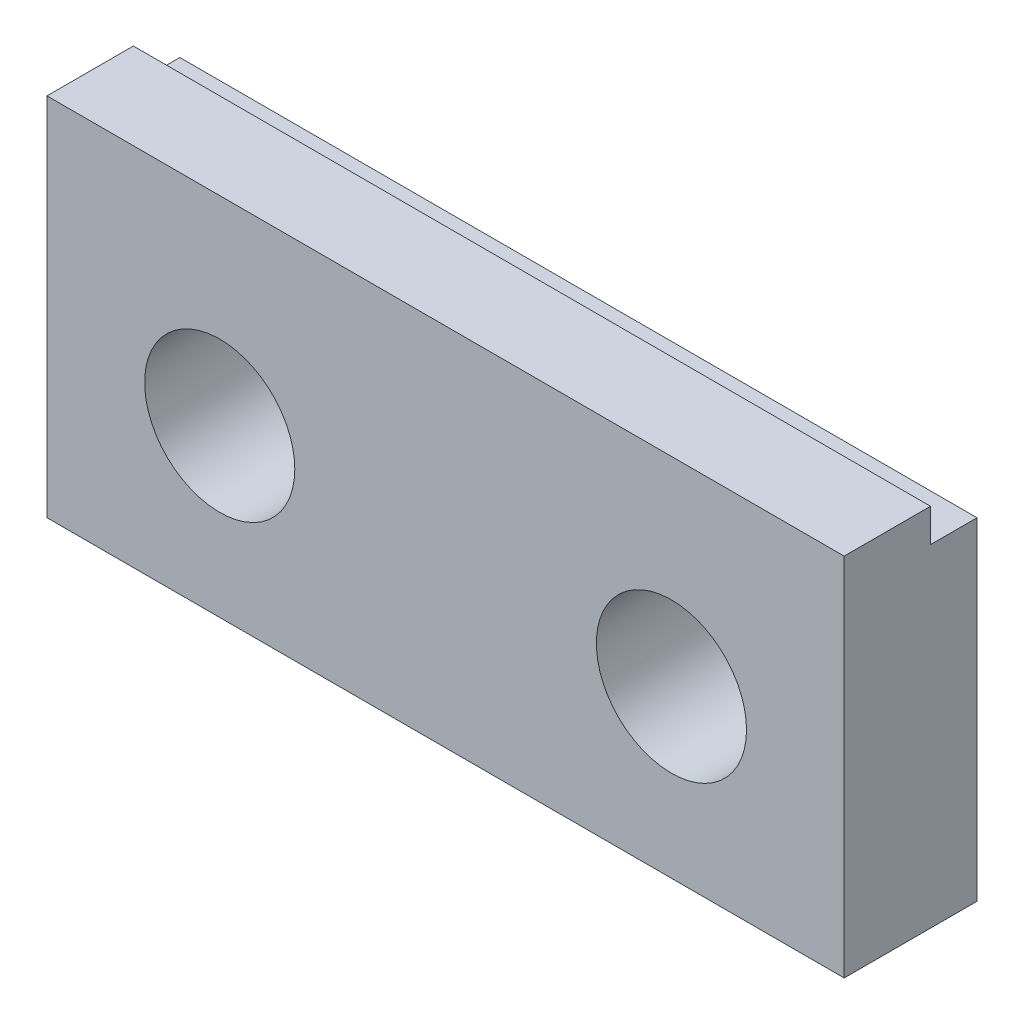
from build123d import *

# Parameters (mm, degrees)
SKETCH1_W      = 12
SKETCH1_H      = 5.5
EXTRUDE1_DEPTH = 2
SKETCH2_R      = 1.1303
EXTRUDE2_DEPTH = 3
SKETCH3_W      = 0.7
SKETCH3_H      = 0.5
EXTRUDE3_DEPTH = 13


with BuildPart() as part:
    # Sketch1 → Extrude1 (new body)
    with BuildSketch(Plane.XY):
        with Locations((0, 0.25)):
            Rectangle(SKETCH1_W, SKETCH1_H)
    extrude(amount=-EXTRUDE1_DEPTH)

    # Sketch2 → Extrude2 (cut, through all)
    with BuildSketch(Plane.XY):
        with Locations((-3.4, 0)):
            Circle(SKETCH2_R)
        with Locations((3.4, 0)):
            Circle(SKETCH2_R)
    extrude(amount=-EXTRUDE2_DEPTH, mode=Mode.SUBTRACT)

    # Sketch3 → Extrude3 (cut, through all)
    with BuildSketch(Plane(origin=(6, 0, 0), x_dir=(0, 0, -1), z_dir=(1, 0, 0))):
        with Locations((1.65, 2.75)):
            Rectangle(SKETCH3_W, SKETCH3_H)
    extrude(amount=-EXTRUDE3_DEPTH, mode=Mode.SUBTRACT)


solid = part.part
